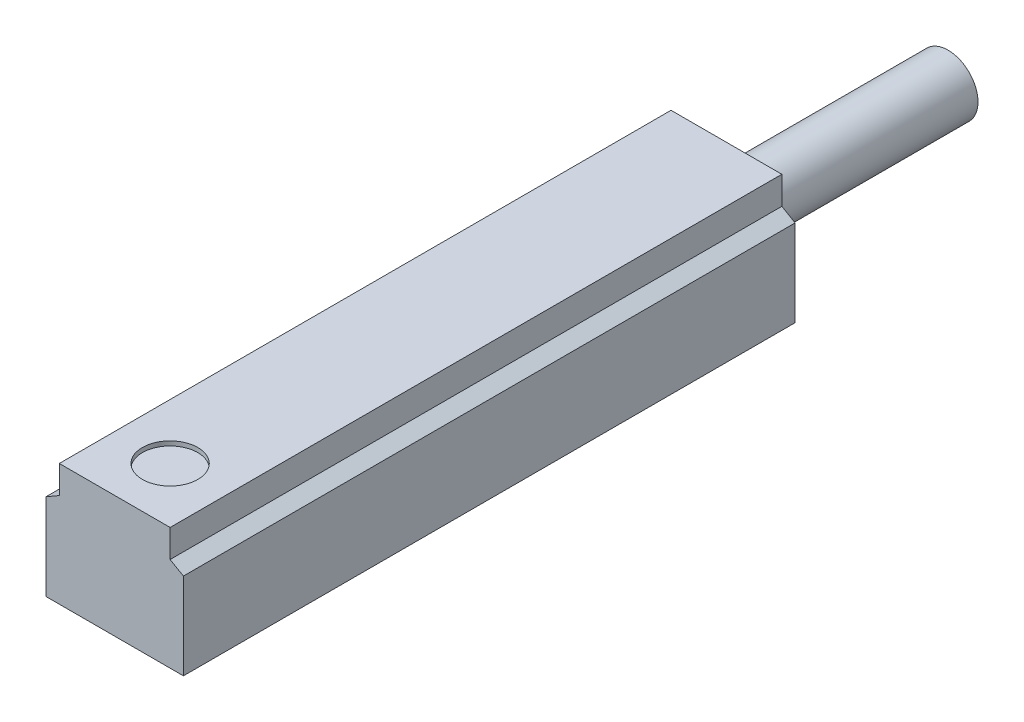
from build123d import *

# Parameters (mm, degrees)
EXTRUDE_1_DEPTH = 27.6
SKETCH_2_W      = 10
SKETCH_2_H      = 1.35
SKETCH_3_W      = 1.25
SKETCH_3_H      = 0.2


with BuildPart() as part:
    # 草图1 → 凸台-拉伸1 (new body)
    with BuildSketch(Plane.XY):
        Polygon((-3.1, 0), (3.1, 0), (3.1, 3.9), (2.5, 4.246410162), (2.5, 5.5), (-2.5, 5.5), (-2.5, 4.246410162), (-3.1, 3.9), align=None)
    extrude(amount=-EXTRUDE_1_DEPTH)

    # 草图2 → 旋转1 (revolve)
    with BuildSketch(Plane(origin=(0, 0, 0), x_dir=(0, 0, -1), z_dir=(1, 0, 0))):
        with Locations((32.6, 3.425)):
            Rectangle(SKETCH_2_W, SKETCH_2_H)
    revolve(axis=Axis((0, 2.75, -37.6), (0, 0, 1)))

    # 草图3 → 切除-旋转1 (revolve, cut)
    with BuildSketch(Plane(origin=(0, 0, 0), x_dir=(0, 0, -1), z_dir=(1, 0, 0))):
        with Locations((3.125, 5.4)):
            Rectangle(SKETCH_3_W, SKETCH_3_H)
    revolve(axis=Axis((0, 5.3, -2.5), (0, 1, 0)), mode=Mode.SUBTRACT)


solid = part.part
